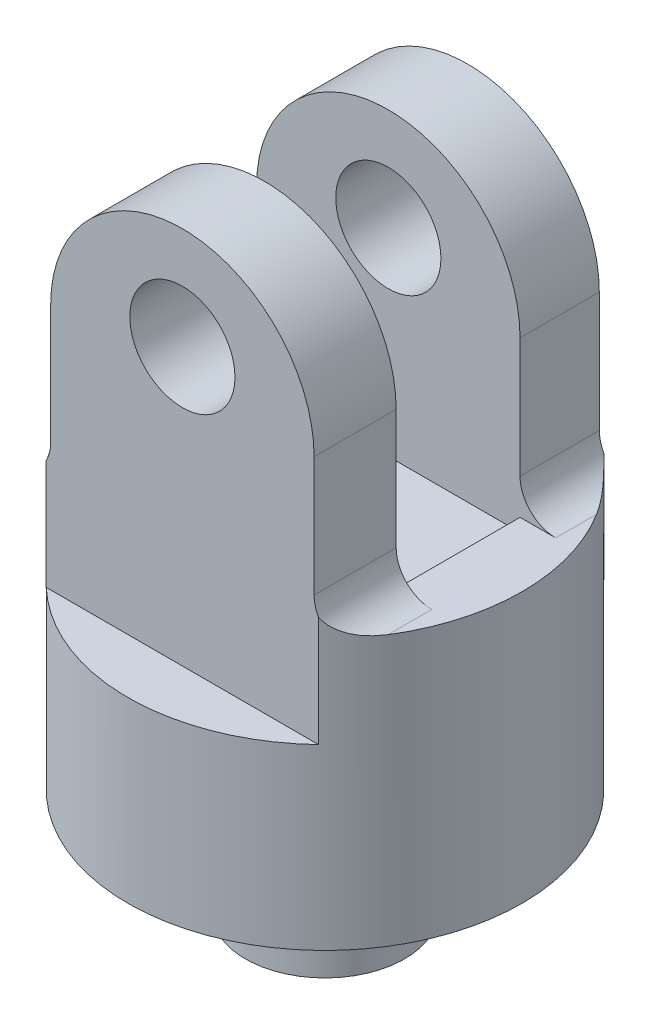
from build123d import *

# Parameters (mm, degrees)
BOSS_EXTRUDE1_DEPTH = 80
SKETCH2_R           = 14.752980174
CUT_EXTRUDE1_DEPTH  = 80
SKETCH3_R           = 55.298116799
BOSS_EXTRUDE2_DEPTH = 50
SKETCH4_R           = 22.325866005
BOSS_EXTRUDE3_DEPTH = 30
CUT_EXTRUDE2_DEPTH  = 30
CUT_EXTRUDE3_DEPTH  = 30
CUT_EXTRUDE4_DEPTH  = 30
CUT_EXTRUDE5_DEPTH  = 30
SKETCH11_W          = 73.883790911
SKETCH11_H          = 34.739224631
CUT_EXTRUDE9_DEPTH  = 110
FILLET1_R           = 10
SKETCH12_R          = 9.507720781
CUT_EXTRUDE10_DEPTH = 110


with BuildPart() as part:
    # Sketch1 → Boss-Extrude1 (new body)
    with BuildSketch(Plane.XY):
        with BuildLine():
            Line((-53.691947432, 3.671244269), (-35.335726088, 3.671244269))
            Line((-35.335726088, 3.671244269), (-35.335726088, 47.267269961))
            ThreePointArc((-35.335726088, 47.267269961), (1.606169368, 84.209165417), (38.548064823, 47.267269961))
            Line((38.548064823, 47.267269961), (38.548064823, 3.671244269))
            Line((38.548064823, 3.671244269), (56.904286167, 3.671244269))
            Line((56.904286167, 3.671244269), (56.904286167, -22.027465613))
            Line((56.904286167, -22.027465613), (-53.691947432, -22.027465613))
            Line((-53.691947432, -22.027465613), (-53.691947432, 3.671244269))
        make_face()
    extrude(amount=-BOSS_EXTRUDE1_DEPTH)

    # Sketch2 → Cut-Extrude1 (cut)
    with BuildSketch(Plane.XY):
        with Locations((1.606169368, 55.478429373)):
            Circle(SKETCH2_R)
    extrude(amount=-CUT_EXTRUDE1_DEPTH, mode=Mode.SUBTRACT)

    # Sketch3 → Boss-Extrude2 (add)
    with BuildSketch(Plane.XZ.offset(22.027465613)):
        with Locations((1.606169368, -40)):
            Circle(SKETCH3_R)
    extrude(amount=BOSS_EXTRUDE2_DEPTH)

    # Sketch4 → Boss-Extrude3 (add)
    with BuildSketch(Plane.XZ.offset(72.027465613)):
        with Locations((1.606169368, -40)):
            Circle(SKETCH4_R)
    extrude(amount=BOSS_EXTRUDE3_DEPTH)

    # Sketch5 → Cut-Extrude2 (cut)
    with BuildSketch(Plane.XZ.offset(22.027465613)):
        with BuildLine():
            Line((-36.57604798, 0), (-53.691947432, 0))
            Line((-53.691947432, 0), (-53.691947432, -40))
            ThreePointArc((-53.691947432, -40), (-49.233217116, -18.245954318), (-36.57604798, 0))
        make_face()
    extrude(amount=-CUT_EXTRUDE2_DEPTH, mode=Mode.SUBTRACT)

    # Sketch6 → Cut-Extrude3 (cut)
    with BuildSketch(Plane.XZ.offset(22.027465613)):
        with BuildLine():
            Line((-36.57604798, -80), (-53.691947432, -80))
            Line((-53.691947432, -80), (-53.691947432, -40))
            ThreePointArc((-53.691947432, -40), (-49.233217116, -61.754045682), (-36.57604798, -80))
        make_face()
    extrude(amount=-CUT_EXTRUDE3_DEPTH, mode=Mode.SUBTRACT)

    # Sketch7 → Cut-Extrude4 (cut)
    with BuildSketch(Plane.XZ.offset(22.027465613)):
        with BuildLine():
            Line((56.904286167, -40), (56.904286167, 0))
            Line((56.904286167, 0), (39.788386715, 0))
            ThreePointArc((39.788386715, 0), (52.445555851, -18.245954318), (56.904286167, -40))
        make_face()
    extrude(amount=-CUT_EXTRUDE4_DEPTH, mode=Mode.SUBTRACT)

    # Sketch8 → Cut-Extrude5 (cut)
    with BuildSketch(Plane.XZ.offset(22.027465613)):
        with BuildLine():
            Line((39.788386715, -80), (56.904286167, -80))
            Line((56.904286167, -80), (56.904286167, -40))
            ThreePointArc((56.904286167, -40), (52.445555851, -61.754045682), (39.788386715, -80))
        make_face()
    extrude(amount=-CUT_EXTRUDE5_DEPTH, mode=Mode.SUBTRACT)

    # Sketch11 → Cut-Extrude9 (cut)
    with BuildSketch(Plane(origin=(0, 0, 0), x_dir=(1, 0, 0), z_dir=(0, 1, 0))):
        with Locations((1.606169368, 40.391795767)):
            Rectangle(SKETCH11_W, SKETCH11_H)
    extrude(amount=CUT_EXTRUDE9_DEPTH, mode=Mode.SUBTRACT)

    # Fillet1
    fillet1_edges = [part.edges().sort_by_distance(p)[0] for p in [
        (-35.335726088, 3.671244269, -68.880704041),
        (38.548064823, 3.671244269, -68.880704041),
        (38.548064823, 3.671244269, -11.511091725),
        (-35.335726088, 3.671244269, -11.511091725),
    ]]
    fillet(fillet1_edges, radius=FILLET1_R)

    # Sketch12 → Cut-Extrude10 (cut)
    with BuildSketch(Plane.XZ.offset(102.027465613)):
        with Locations((1.606169368, -40)):
            Circle(SKETCH12_R)
    extrude(amount=-CUT_EXTRUDE10_DEPTH, mode=Mode.SUBTRACT)


solid = part.part
